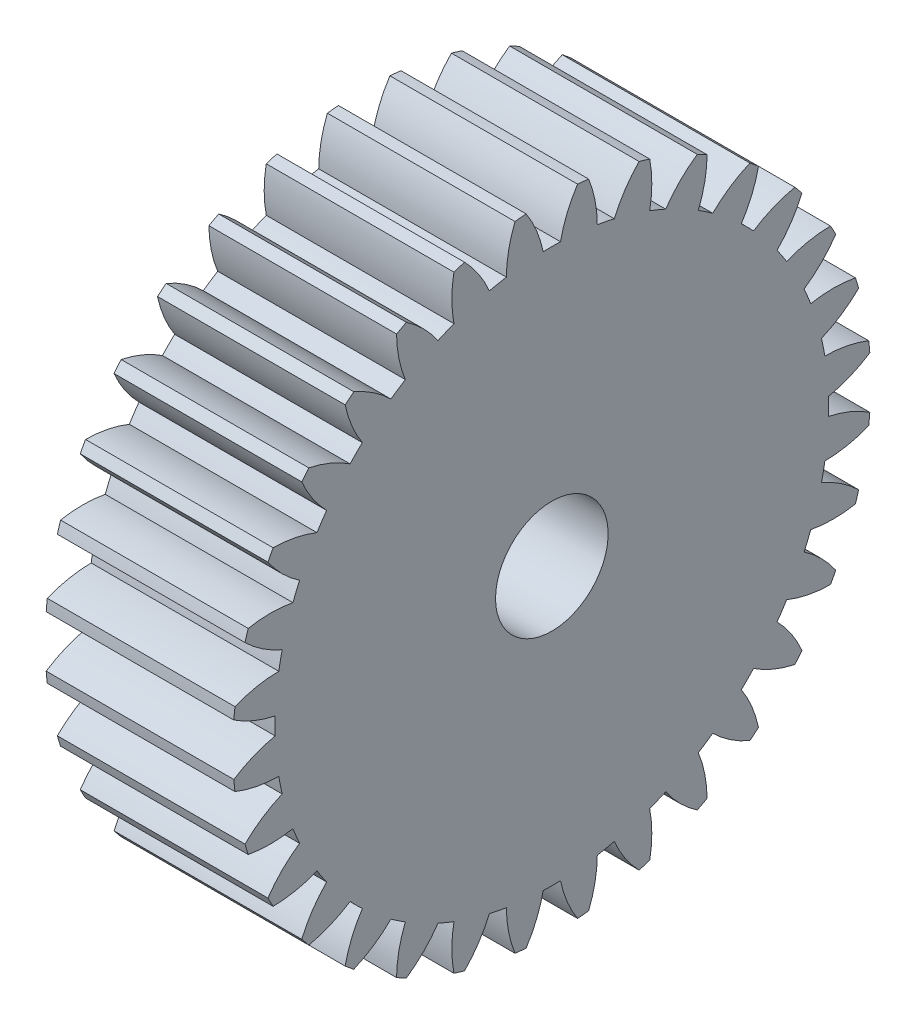
from build123d import *

# Parameters (mm, degrees)
BASPROSKE_W     = 10
BASPROSKE_H     = 17
TOOTHCUT_DEPTH  = 27.038433133
TEETHCUTS_COUNT = 32
TEETHCUTS_ANGLE = 348.75
BORSKE_R        = 3
BORE_DEPTH      = 50.0000508


with BuildPart() as part:
    # BasProSke → Base-Revolve (revolve)
    with BuildSketch(Plane(origin=(0, 0, 0), x_dir=(1, 0, 0), z_dir=(0, 1, 0)), mode=Mode.PRIVATE) as base_revolve_sk:
        with Locations((5, 8.5)):
            Rectangle(BASPROSKE_W, BASPROSKE_H)
    revolve(base_revolve_sk.sketch.rotate(Axis((-10, 0, 0), (1, 0, 0)), 180), axis=Axis((-10, 0, 0), (1, 0, 0)))

    # TooCutSke → ToothCut (cut, through all)
    with BuildSketch(Plane(origin=(0, 0, 0), x_dir=(0, 0, -1), z_dir=(1, 0, 0))):
        with BuildLine():
            ThreePointArc((0.462036907, 14.741761187), (0, 14.749), (-0.462036907, 14.741761187))
            ThreePointArc((-0.462036907, 14.741761187), (-0.81854142, 15.899240468), (-1.386721275, 16.9688317))
            ThreePointArc((-1.386721275, 16.9688317), (0, 17.0254), (1.386721275, 16.9688317))
            ThreePointArc((1.386721275, 16.9688317), (0.81854142, 15.899240468), (0.462036907, 14.741761187))
        make_face()
    toothcut = extrude(amount=TOOTHCUT_DEPTH, mode=Mode.SUBTRACT)

    # TeethCuts: ToothCut ×32 about axis
    teethcuts_axis = Axis((-10, 0, 0), (1, 0, 0))
    for i in range(1, TEETHCUTS_COUNT):
        add(toothcut.rotate(teethcuts_axis, i * TEETHCUTS_ANGLE / (TEETHCUTS_COUNT - 1)), mode=Mode.SUBTRACT)

    # BorSke → Bore (cut, symmetric)
    with BuildSketch(Plane(origin=(0, 0, 0), x_dir=(0, 0, -1), z_dir=(1, 0, 0))):
        with Locations(Location((0, 0, 0), (0, 0, 180))):
            Circle(BORSKE_R)
    extrude(amount=BORE_DEPTH, both=True, mode=Mode.SUBTRACT)


solid = part.part
